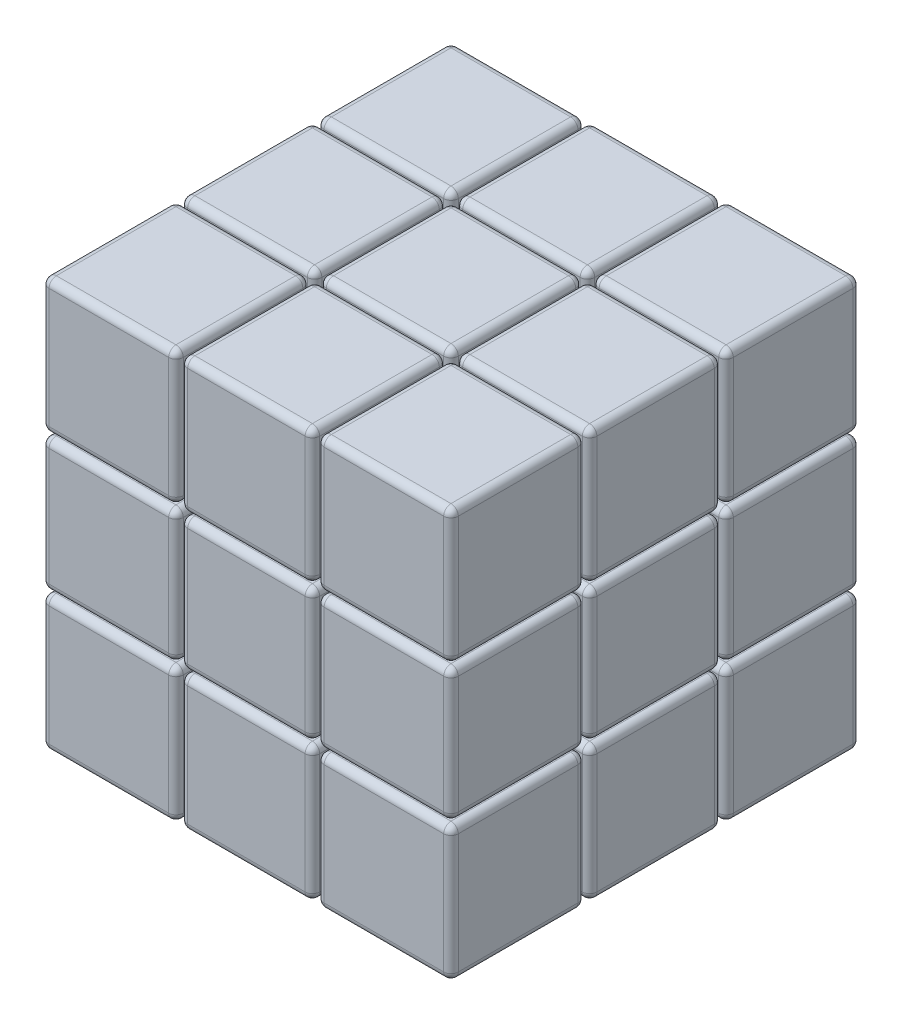
from build123d import *

# Parameters (mm, degrees)
SKETCH1_W           = 56
SKETCH1_H           = 56
BOSS_EXTRUDE1_DEPTH = 56
SKETCH2_W           = 18.066666666
SKETCH2_H           = 18.066666666
CUT_EXTRUDE1_DEPTH  = 56
SKETCH3_W           = 0.6
SKETCH3_H           = 56
CUT_EXTRUDE2_DEPTH  = 56
FILLET2_R           = 1
FILLET3_R           = 1
FILLET4_R           = 1
FILLET5_R           = 1
FILLET6_R           = 1
FILLET7_R           = 1
FILLET8_R           = 1
FILLET9_R           = 1
FILLET10_R          = 1
FILLET11_R          = 1
FILLET12_R          = 1
FILLET13_R          = 1
FILLET14_R          = 1
FILLET15_R          = 1
FILLET16_R          = 1
FILLET17_R          = 1
FILLET18_R          = 1
FILLET19_R          = 1
FILLET20_R          = 1
FILLET21_R          = 1
FILLET22_R          = 1
FILLET23_R          = 1
FILLET24_R          = 1
FILLET25_R          = 1
FILLET26_R          = 1
FILLET27_R          = 1
FILLET28_R          = 1


with BuildPart() as part:
    # Sketch1 → Boss-Extrude1 (new body)
    with BuildSketch(Plane(origin=(0, 0, 0), x_dir=(1, 0, 0), z_dir=(0, 1, 0))):
        with Locations((28, 28)):
            Rectangle(SKETCH1_W, SKETCH1_H)
    extrude(amount=BOSS_EXTRUDE1_DEPTH)

    # Sketch2 → Cut-Extrude1 (cut)
    with BuildSketch(Plane.XY):
        Polygon((37.633333333, 18.966666667), (56, 18.966666667), (56, 18.366666667), (37.633333333, 18.366666667), (37.633333333, 0), (37.033333333, 0), (37.033333333, 18.366666667), (18.966666667, 18.366666667), (18.966666667, 0), (18.366666667, 0), (18.366666667, 18.366666667), (0, 18.366666667), (0, 18.966666667), (18.366666667, 18.966666667), (18.366666667, 37.033333333), (0, 37.033333333), (0, 37.633333333), (18.366666667, 37.633333333), (18.366666667, 56), (18.966666667, 56), (18.966666667, 37.633333333), (37.033333333, 37.633333333), (37.033333333, 56), (37.633333333, 56), (37.633333333, 37.633333333), (56, 37.633333333), (56, 37.033333333), (37.633333333, 37.033333333), align=None)
        with Locations((28, 28)):
            Rectangle(SKETCH2_W, SKETCH2_H, mode=Mode.SUBTRACT)
    extrude(amount=-CUT_EXTRUDE1_DEPTH, mode=Mode.SUBTRACT)

    # Sketch3 → Cut-Extrude2 (cut)
    with BuildSketch(Plane.ZY):
        with Locations((-37.333333333, 28)):
            Rectangle(SKETCH3_W, SKETCH3_H)
        with Locations((-18.666666667, 28)):
            Rectangle(SKETCH3_W, SKETCH3_H)
    extrude(amount=-CUT_EXTRUDE2_DEPTH, mode=Mode.SUBTRACT)

    # Fillet2
    fillet2_edges = [part.edges().sort_by_distance(p)[0] for p in [
        (9.183333333, 37.633333333, -18.366666667),
        (18.366666667, 37.633333333, -9.183333333),
        (9.183333333, 37.633333333, 0),
        (18.366666667, 46.816666667, -18.366666667),
        (18.366666667, 56, -9.183333333),
        (18.366666667, 46.816666667, 0),
        (0, 37.633333333, -9.183333333),
        (9.183333333, 56, -18.366666667),
        (0, 56, -9.183333333),
        (9.183333333, 56, 0),
        (0, 46.816666667, -18.366666667),
        (0, 46.816666667, 0),
    ]]
    fillet(fillet2_edges, radius=FILLET2_R)

    # Fillet3
    fillet3_edges = [part.edges().sort_by_distance(p)[0] for p in [
        (18.366666667, 18.366666667, -28),
        (0, 18.366666667, -28),
        (9.183333333, 18.366666667, -18.966666667),
        (9.183333333, 18.366666667, -37.033333333),
        (18.366666667, 0, -28),
        (0, 0, -28),
        (9.183333333, 0, -37.033333333),
        (18.366666667, 9.183333333, -37.033333333),
        (0, 9.183333333, -37.033333333),
        (18.366666667, 9.183333333, -18.966666667),
        (9.183333333, 0, -18.966666667),
        (0, 9.183333333, -18.966666667),
    ]]
    fillet(fillet3_edges, radius=FILLET3_R)

    # Fillet4
    fillet4_edges = [part.edges().sort_by_distance(p)[0] for p in [
        (37.633333333, 37.633333333, -28),
        (56, 37.633333333, -28),
        (46.816666667, 37.633333333, -18.966666667),
        (46.816666667, 37.633333333, -37.033333333),
        (37.633333333, 56, -28),
        (56, 56, -28),
        (46.816666667, 56, -37.033333333),
        (37.633333333, 46.816666667, -37.033333333),
        (56, 46.816666667, -37.033333333),
        (46.816666667, 56, -18.966666667),
        (37.633333333, 46.816666667, -18.966666667),
        (56, 46.816666667, -18.966666667),
    ]]
    fillet(fillet4_edges, radius=FILLET4_R)

    # Fillet5
    fillet5_edges = [part.edges().sort_by_distance(p)[0] for p in [
        (37.033333333, 18.966666667, -46.816666667),
        (37.033333333, 28, -56),
        (37.033333333, 37.033333333, -46.816666667),
        (28, 37.033333333, -56),
        (18.966666667, 37.033333333, -46.816666667),
        (18.966666667, 28, -56),
        (18.966666667, 18.966666667, -46.816666667),
        (28, 18.966666667, -37.633333333),
        (37.033333333, 28, -37.633333333),
        (28, 37.033333333, -37.633333333),
        (18.966666667, 28, -37.633333333),
        (28, 18.966666667, -56),
    ]]
    fillet(fillet5_edges, radius=FILLET5_R)

    # Fillet6
    fillet6_edges = [part.edges().sort_by_distance(p)[0] for p in [
        (0, 9.183333333, -56),
        (9.183333333, 0, -37.633333333),
        (18.366666667, 0, -46.816666667),
        (18.366666667, 18.366666667, -46.816666667),
        (18.366666667, 9.183333333, -37.633333333),
        (0, 18.366666667, -46.816666667),
        (9.183333333, 18.366666667, -37.633333333),
        (9.183333333, 18.366666667, -56),
        (18.366666667, 9.183333333, -56),
        (9.183333333, 0, -56),
        (0, 9.183333333, -37.633333333),
        (0, 0, -46.816666667),
    ]]
    fillet(fillet6_edges, radius=FILLET6_R)

    # Fillet7
    fillet7_edges = [part.edges().sort_by_distance(p)[0] for p in [
        (56, 37.633333333, -9.183333333),
        (46.816666667, 37.633333333, 0),
        (37.633333333, 46.816666667, -18.366666667),
        (37.633333333, 37.633333333, -9.183333333),
        (37.633333333, 46.816666667, 0),
        (56, 46.816666667, -18.366666667),
        (56, 46.816666667, 0),
        (56, 56, -9.183333333),
        (46.816666667, 56, -18.366666667),
        (37.633333333, 56, -9.183333333),
        (46.816666667, 56, 0),
        (46.816666667, 37.633333333, -18.366666667),
    ]]
    fillet(fillet7_edges, radius=FILLET7_R)

    # Fillet8
    fillet8_edges = [part.edges().sort_by_distance(p)[0] for p in [
        (18.966666667, 37.633333333, -28),
        (37.033333333, 37.633333333, -28),
        (28, 37.633333333, -18.966666667),
        (28, 37.633333333, -37.033333333),
        (37.033333333, 56, -28),
        (18.966666667, 56, -28),
        (28, 56, -37.033333333),
        (18.966666667, 46.816666667, -37.033333333),
        (37.033333333, 46.816666667, -37.033333333),
        (28, 56, -18.966666667),
        (18.966666667, 46.816666667, -18.966666667),
        (37.033333333, 46.816666667, -18.966666667),
    ]]
    fillet(fillet8_edges, radius=FILLET8_R)

    # Fillet9
    fillet9_edges = [part.edges().sort_by_distance(p)[0] for p in [
        (37.033333333, 37.633333333, -9.183333333),
        (28, 37.633333333, 0),
        (37.033333333, 46.816666667, -18.366666667),
        (37.033333333, 56, -9.183333333),
        (37.033333333, 46.816666667, 0),
        (18.966666667, 46.816666667, -18.366666667),
        (18.966666667, 37.633333333, -9.183333333),
        (18.966666667, 46.816666667, 0),
        (28, 56, -18.366666667),
        (18.966666667, 56, -9.183333333),
        (28, 56, 0),
        (28, 37.633333333, -18.366666667),
    ]]
    fillet(fillet9_edges, radius=FILLET9_R)

    # Fillet10
    fillet10_edges = [part.edges().sort_by_distance(p)[0] for p in [
        (9.183333333, 18.966666667, -18.366666667),
        (18.366666667, 18.966666667, -9.183333333),
        (9.183333333, 18.966666667, 0),
        (18.366666667, 28, -18.366666667),
        (18.366666667, 37.033333333, -9.183333333),
        (18.366666667, 28, 0),
        (9.183333333, 37.033333333, -18.366666667),
        (0, 37.033333333, -9.183333333),
        (9.183333333, 37.033333333, 0),
        (0, 18.966666667, -9.183333333),
        (0, 28, -18.366666667),
        (0, 28, 0),
    ]]
    fillet(fillet10_edges, radius=FILLET10_R)

    # Fillet11
    fillet11_edges = [part.edges().sort_by_distance(p)[0] for p in [
        (56, 28, -37.633333333),
        (37.633333333, 37.033333333, -46.816666667),
        (46.816666667, 37.033333333, -37.633333333),
        (37.633333333, 18.966666667, -46.816666667),
        (37.633333333, 28, -37.633333333),
        (56, 18.966666667, -46.816666667),
        (46.816666667, 18.966666667, -37.633333333),
        (37.633333333, 28, -56),
        (46.816666667, 37.033333333, -56),
        (56, 28, -56),
        (46.816666667, 18.966666667, -56),
        (56, 37.033333333, -46.816666667),
    ]]
    fillet(fillet11_edges, radius=FILLET11_R)

    # Fillet12
    fillet12_edges = [part.edges().sort_by_distance(p)[0] for p in [
        (37.033333333, 0, -46.816666667),
        (37.033333333, 18.366666667, -46.816666667),
        (37.033333333, 9.183333333, -37.633333333),
        (18.966666667, 0, -46.816666667),
        (18.966666667, 9.183333333, -37.633333333),
        (18.966666667, 18.366666667, -46.816666667),
        (28, 18.366666667, -37.633333333),
        (28, 18.366666667, -56),
        (37.033333333, 9.183333333, -56),
        (28, 0, -56),
        (18.966666667, 9.183333333, -56),
        (28, 0, -37.633333333),
    ]]
    fillet(fillet12_edges, radius=FILLET12_R)

    # Fillet13
    fillet13_edges = [part.edges().sort_by_distance(p)[0] for p in [
        (37.033333333, 18.366666667, -28),
        (18.966666667, 18.366666667, -28),
        (28, 18.366666667, -18.966666667),
        (28, 18.366666667, -37.033333333),
        (18.966666667, 0, -28),
        (37.033333333, 0, -28),
        (28, 0, -37.033333333),
        (37.033333333, 9.183333333, -37.033333333),
        (18.966666667, 9.183333333, -37.033333333),
        (37.033333333, 9.183333333, -18.966666667),
        (28, 0, -18.966666667),
        (18.966666667, 9.183333333, -18.966666667),
    ]]
    fillet(fillet13_edges, radius=FILLET13_R)

    # Fillet14
    fillet14_edges = [part.edges().sort_by_distance(p)[0] for p in [
        (56, 18.366666667, -46.816666667),
        (56, 9.183333333, -37.633333333),
        (56, 0, -46.816666667),
        (37.633333333, 0, -46.816666667),
        (37.633333333, 9.183333333, -37.633333333),
        (37.633333333, 18.366666667, -46.816666667),
        (46.816666667, 18.366666667, -37.633333333),
        (37.633333333, 9.183333333, -56),
        (46.816666667, 18.366666667, -56),
        (56, 9.183333333, -56),
        (46.816666667, 0, -56),
        (46.816666667, 0, -37.633333333),
    ]]
    fillet(fillet14_edges, radius=FILLET14_R)

    # Fillet15
    fillet15_edges = [part.edges().sort_by_distance(p)[0] for p in [
        (28, 18.966666667, 0),
        (37.033333333, 28, 0),
        (28, 37.033333333, 0),
        (18.966666667, 18.966666667, -9.183333333),
        (18.966666667, 37.033333333, -9.183333333),
        (37.033333333, 37.033333333, -9.183333333),
        (37.033333333, 18.966666667, -9.183333333),
        (28, 18.966666667, -18.366666667),
        (18.966666667, 28, -18.366666667),
        (28, 37.033333333, -18.366666667),
        (37.033333333, 28, -18.366666667),
        (18.966666667, 28, 0),
    ]]
    fillet(fillet15_edges, radius=FILLET15_R)

    # Fillet16
    fillet16_edges = [part.edges().sort_by_distance(p)[0] for p in [
        (18.966666667, 37.033333333, -28),
        (18.966666667, 18.966666667, -28),
        (18.966666667, 28, -18.966666667),
        (18.966666667, 28, -37.033333333),
        (37.033333333, 37.033333333, -28),
        (37.033333333, 18.966666667, -28),
        (37.033333333, 28, -37.033333333),
        (28, 18.966666667, -37.033333333),
        (28, 37.033333333, -37.033333333),
        (28, 18.966666667, -18.966666667),
        (37.033333333, 28, -18.966666667),
        (28, 37.033333333, -18.966666667),
    ]]
    fillet(fillet16_edges, radius=FILLET16_R)

    # Fillet17
    fillet17_edges = [part.edges().sort_by_distance(p)[0] for p in [
        (0, 9.183333333, 0),
        (9.183333333, 18.366666667, -18.366666667),
        (0, 18.366666667, -9.183333333),
        (9.183333333, 18.366666667, 0),
        (18.366666667, 9.183333333, -18.366666667),
        (18.366666667, 18.366666667, -9.183333333),
        (18.366666667, 9.183333333, 0),
        (18.366666667, 0, -9.183333333),
        (0, 0, -9.183333333),
        (9.183333333, 0, -18.366666667),
        (0, 9.183333333, -18.366666667),
        (9.183333333, 0, 0),
    ]]
    fillet(fillet17_edges, radius=FILLET17_R)

    # Fillet18
    fillet18_edges = [part.edges().sort_by_distance(p)[0] for p in [
        (9.183333333, 56, -56),
        (0, 37.633333333, -46.816666667),
        (0, 46.816666667, -56),
        (18.366666667, 56, -46.816666667),
        (18.366666667, 46.816666667, -37.633333333),
        (18.366666667, 37.633333333, -46.816666667),
        (9.183333333, 37.633333333, -37.633333333),
        (18.366666667, 46.816666667, -56),
        (9.183333333, 37.633333333, -56),
        (9.183333333, 56, -37.633333333),
        (0, 46.816666667, -37.633333333),
        (0, 56, -46.816666667),
    ]]
    fillet(fillet18_edges, radius=FILLET18_R)

    # Fillet19
    fillet19_edges = [part.edges().sort_by_distance(p)[0] for p in [
        (37.633333333, 18.966666667, -28),
        (56, 18.966666667, -28),
        (46.816666667, 18.966666667, -18.966666667),
        (46.816666667, 18.966666667, -37.033333333),
        (37.633333333, 37.033333333, -28),
        (56, 37.033333333, -28),
        (56, 28, -37.033333333),
        (46.816666667, 37.033333333, -37.033333333),
        (37.633333333, 28, -37.033333333),
        (37.633333333, 28, -18.966666667),
        (46.816666667, 37.033333333, -18.966666667),
        (56, 28, -18.966666667),
    ]]
    fillet(fillet19_edges, radius=FILLET19_R)

    # Fillet20
    fillet20_edges = [part.edges().sort_by_distance(p)[0] for p in [
        (0, 37.633333333, -28),
        (18.366666667, 37.633333333, -28),
        (9.183333333, 37.633333333, -18.966666667),
        (9.183333333, 37.633333333, -37.033333333),
        (18.366666667, 56, -28),
        (0, 56, -28),
        (18.366666667, 46.816666667, -37.033333333),
        (9.183333333, 56, -37.033333333),
        (0, 46.816666667, -37.033333333),
        (9.183333333, 56, -18.966666667),
        (18.366666667, 46.816666667, -18.966666667),
        (0, 46.816666667, -18.966666667),
    ]]
    fillet(fillet20_edges, radius=FILLET20_R)

    # Fillet21
    fillet21_edges = [part.edges().sort_by_distance(p)[0] for p in [
        (56, 56, -46.816666667),
        (46.816666667, 56, -56),
        (56, 46.816666667, -37.633333333),
        (37.633333333, 37.633333333, -46.816666667),
        (37.633333333, 46.816666667, -37.633333333),
        (56, 37.633333333, -46.816666667),
        (46.816666667, 37.633333333, -37.633333333),
        (46.816666667, 37.633333333, -56),
        (37.633333333, 46.816666667, -56),
        (56, 46.816666667, -56),
        (46.816666667, 56, -37.633333333),
        (37.633333333, 56, -46.816666667),
    ]]
    fillet(fillet21_edges, radius=FILLET21_R)

    # Fillet22
    fillet22_edges = [part.edges().sort_by_distance(p)[0] for p in [
        (56, 18.966666667, -9.183333333),
        (46.816666667, 18.966666667, 0),
        (37.633333333, 28, -18.366666667),
        (37.633333333, 18.966666667, -9.183333333),
        (37.633333333, 28, 0),
        (46.816666667, 37.033333333, -18.366666667),
        (37.633333333, 37.033333333, -9.183333333),
        (46.816666667, 37.033333333, 0),
        (56, 28, -18.366666667),
        (56, 37.033333333, -9.183333333),
        (56, 28, 0),
        (46.816666667, 18.966666667, -18.366666667),
    ]]
    fillet(fillet22_edges, radius=FILLET22_R)

    # Fillet23
    fillet23_edges = [part.edges().sort_by_distance(p)[0] for p in [
        (28, 18.366666667, -18.366666667),
        (18.966666667, 18.366666667, -9.183333333),
        (28, 18.366666667, 0),
        (18.966666667, 9.183333333, -18.366666667),
        (18.966666667, 0, -9.183333333),
        (18.966666667, 9.183333333, 0),
        (37.033333333, 9.183333333, -18.366666667),
        (37.033333333, 18.366666667, -9.183333333),
        (37.033333333, 9.183333333, 0),
        (37.033333333, 0, -9.183333333),
        (28, 0, -18.366666667),
        (28, 0, 0),
    ]]
    fillet(fillet23_edges, radius=FILLET23_R)

    # Fillet24
    fillet24_edges = [part.edges().sort_by_distance(p)[0] for p in [
        (56, 18.366666667, -28),
        (37.633333333, 18.366666667, -28),
        (46.816666667, 18.366666667, -18.966666667),
        (46.816666667, 18.366666667, -37.033333333),
        (37.633333333, 0, -28),
        (56, 0, -28),
        (46.816666667, 0, -37.033333333),
        (37.633333333, 9.183333333, -37.033333333),
        (56, 9.183333333, -37.033333333),
        (46.816666667, 0, -18.966666667),
        (37.633333333, 9.183333333, -18.966666667),
        (56, 9.183333333, -18.966666667),
    ]]
    fillet(fillet24_edges, radius=FILLET24_R)

    # Fillet25
    fillet25_edges = [part.edges().sort_by_distance(p)[0] for p in [
        (46.816666667, 18.366666667, -18.366666667),
        (37.633333333, 18.366666667, -9.183333333),
        (46.816666667, 18.366666667, 0),
        (37.633333333, 9.183333333, -18.366666667),
        (37.633333333, 0, -9.183333333),
        (37.633333333, 9.183333333, 0),
        (56, 0, -9.183333333),
        (56, 9.183333333, -18.366666667),
        (56, 18.366666667, -9.183333333),
        (56, 9.183333333, 0),
        (46.816666667, 0, -18.366666667),
        (46.816666667, 0, 0),
    ]]
    fillet(fillet25_edges, radius=FILLET25_R)

    # Fillet26
    fillet26_edges = [part.edges().sort_by_distance(p)[0] for p in [
        (0, 18.966666667, -28),
        (18.366666667, 18.966666667, -28),
        (9.183333333, 18.966666667, -18.966666667),
        (9.183333333, 18.966666667, -37.033333333),
        (18.366666667, 37.033333333, -28),
        (0, 37.033333333, -28),
        (18.366666667, 28, -37.033333333),
        (9.183333333, 37.033333333, -37.033333333),
        (0, 28, -37.033333333),
        (9.183333333, 37.033333333, -18.966666667),
        (18.366666667, 28, -18.966666667),
        (0, 28, -18.966666667),
    ]]
    fillet(fillet26_edges, radius=FILLET26_R)

    # Fillet27
    fillet27_edges = [part.edges().sort_by_distance(p)[0] for p in [
        (28, 56, -56),
        (18.966666667, 37.633333333, -46.816666667),
        (18.966666667, 46.816666667, -37.633333333),
        (37.033333333, 56, -46.816666667),
        (37.033333333, 46.816666667, -37.633333333),
        (37.033333333, 37.633333333, -46.816666667),
        (28, 37.633333333, -37.633333333),
        (37.033333333, 46.816666667, -56),
        (28, 37.633333333, -56),
        (18.966666667, 46.816666667, -56),
        (28, 56, -37.633333333),
        (18.966666667, 56, -46.816666667),
    ]]
    fillet(fillet27_edges, radius=FILLET27_R)

    # Fillet28
    fillet28_edges = [part.edges().sort_by_distance(p)[0] for p in [
        (0, 28, -56),
        (0, 37.033333333, -46.816666667),
        (9.183333333, 37.033333333, -37.633333333),
        (18.366666667, 37.033333333, -46.816666667),
        (18.366666667, 28, -37.633333333),
        (18.366666667, 18.966666667, -46.816666667),
        (9.183333333, 18.966666667, -37.633333333),
        (18.366666667, 28, -56),
        (9.183333333, 18.966666667, -56),
        (9.183333333, 37.033333333, -56),
        (0, 28, -37.633333333),
        (0, 18.966666667, -46.816666667),
    ]]
    fillet(fillet28_edges, radius=FILLET28_R)


solid = part.part
